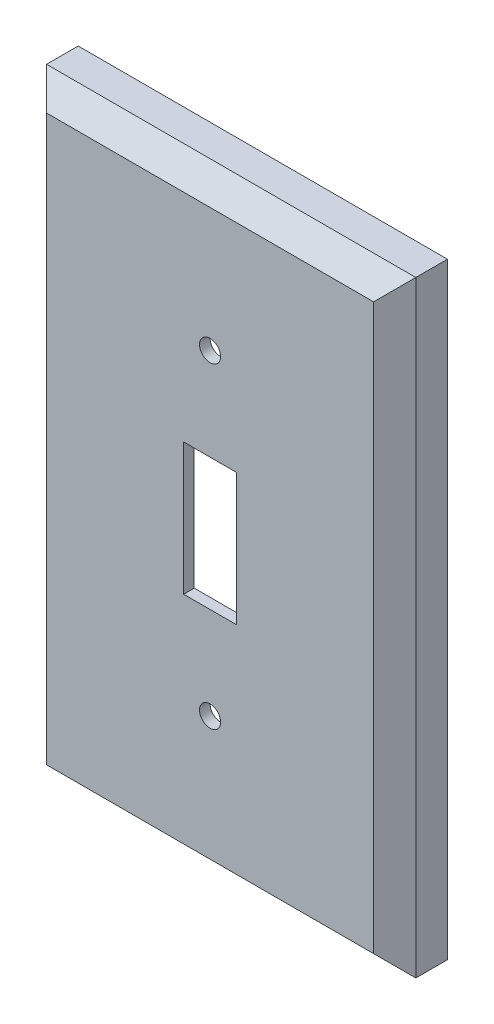
from build123d import *

# Parameters (mm, degrees)
SKETCH1_W             = 70
SKETCH1_H             = 115
BOSS_EXTRUDE1_DEPTH   = 10
CUT_EXTRUDE1_DEPTH    = 8
CHAMFER1_SIZE         = 4
SKETCH2_R             = 2
SKETCH2_W             = 10
SKETCH2_H             = 25
CUT_EXTRUDE2_DEPTH    = 8
BODY_MOVE_COPY1_ANGLE = 90


with BuildPart() as part:
    # Sketch1 → Boss-Extrude1 (new body)
    with BuildSketch(Plane(origin=(0, 0, 0), x_dir=(1, 0, 0), z_dir=(0, 1, 0))):
        with Locations((35, 57.5)):
            Rectangle(SKETCH1_W, SKETCH1_H)
    extrude(amount=BOSS_EXTRUDE1_DEPTH)

    # 3DSketch1 → Cut-Extrude1 (cut)
    with BuildSketch(Plane(origin=(2, 10, -2), x_dir=(0.51107539287715, 0, -0.8595358880206614), z_dir=(0, -1, 0))):
        Polygon((0, 0), (33.73097593, 56.729368609), (129.1394595, 0), (95.40848357, -56.729368609), align=None)
    extrude(amount=CUT_EXTRUDE1_DEPTH, mode=Mode.SUBTRACT)

    # Chamfer1
    chamfer1_edges = [part.edges().sort_by_distance(p)[0] for p in [
        (35, 0, -115),
        (70, 0, -57.5),
        (35, 0, 0),
        (0, 0, -57.5),
    ]]
    chamfer(chamfer1_edges, length=CHAMFER1_SIZE)

    # Sketch2 → Cut-Extrude2 (cut)
    with BuildSketch(Plane(origin=(0, 2, 0), x_dir=(1, 0, 0), z_dir=(0, 1, 0))):
        with Locations(Location((35, 87.5, 0), (0, 0, 270))):
            Circle(SKETCH2_R)
        with Locations(Location((35, 27.5, 0), (0, 0, 270))):
            Circle(SKETCH2_R)
        with Locations((35, 57.5)):
            Rectangle(SKETCH2_W, SKETCH2_H)
    extrude(amount=-CUT_EXTRUDE2_DEPTH, mode=Mode.SUBTRACT)


with BuildPart() as part_1:
    # Body-Move/Copy1: moved
    add(part.part.rotate(Axis((0, 5.000051539, -57.5), (-1, 0, 0)), BODY_MOVE_COPY1_ANGLE))


solid = part_1.part
